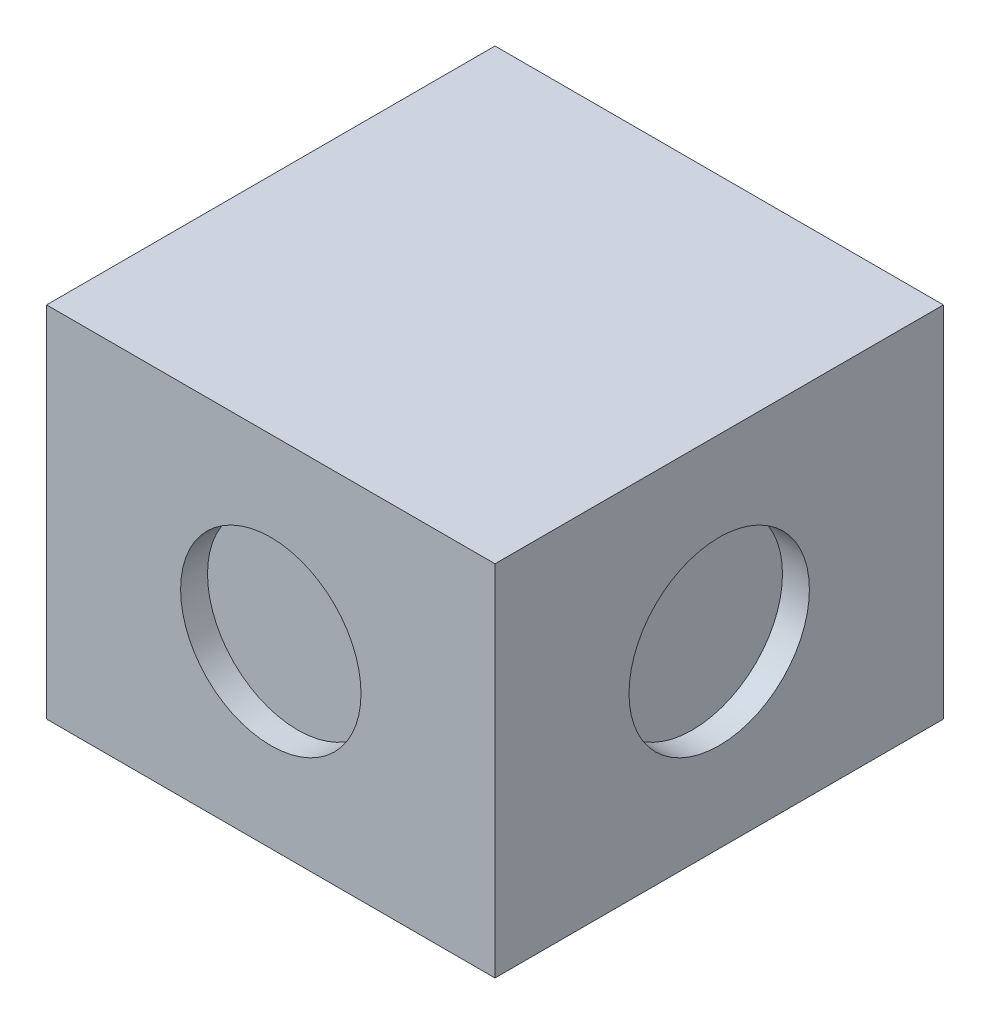
from build123d import *

# Parameters (mm, degrees)
SKETCH1_W           = 50
SKETCH1_H           = 50
BOSS_EXTRUDE1_DEPTH = 40
SKETCH5_R           = 10.057084534
CUT_EXTRUDE1_DEPTH  = 3
SKETCH4_R           = 10.057084534
CUT_EXTRUDE2_DEPTH  = 3
SKETCH2_R           = 17
CUT_EXTRUDE3_DEPTH  = 3


with BuildPart() as part:
    # Sketch1 → Boss-Extrude1 (new body)
    with BuildSketch(Plane(origin=(0, 0, 0), x_dir=(1, 0, 0), z_dir=(0, 1, 0))):
        Rectangle(SKETCH1_W, SKETCH1_H)
    extrude(amount=BOSS_EXTRUDE1_DEPTH)

    # Sketch5 → Cut-Extrude1 (cut)
    with BuildSketch(Plane(origin=(25, 0, 0), x_dir=(0, 0, -1), z_dir=(1, 0, 0))):
        with Locations((0, 20)):
            Circle(SKETCH5_R)
    extrude(amount=-CUT_EXTRUDE1_DEPTH, mode=Mode.SUBTRACT)

    # Sketch4 → Cut-Extrude2 (cut)
    with BuildSketch(Plane.XY.offset(25)):
        with Locations((0, 20)):
            Circle(SKETCH4_R)
    extrude(amount=-CUT_EXTRUDE2_DEPTH, mode=Mode.SUBTRACT)

    # Sketch2 → Cut-Extrude3 (cut)
    with BuildSketch(Plane.XZ):
        Circle(SKETCH2_R)
    extrude(amount=-CUT_EXTRUDE3_DEPTH, mode=Mode.SUBTRACT)


solid = part.part
